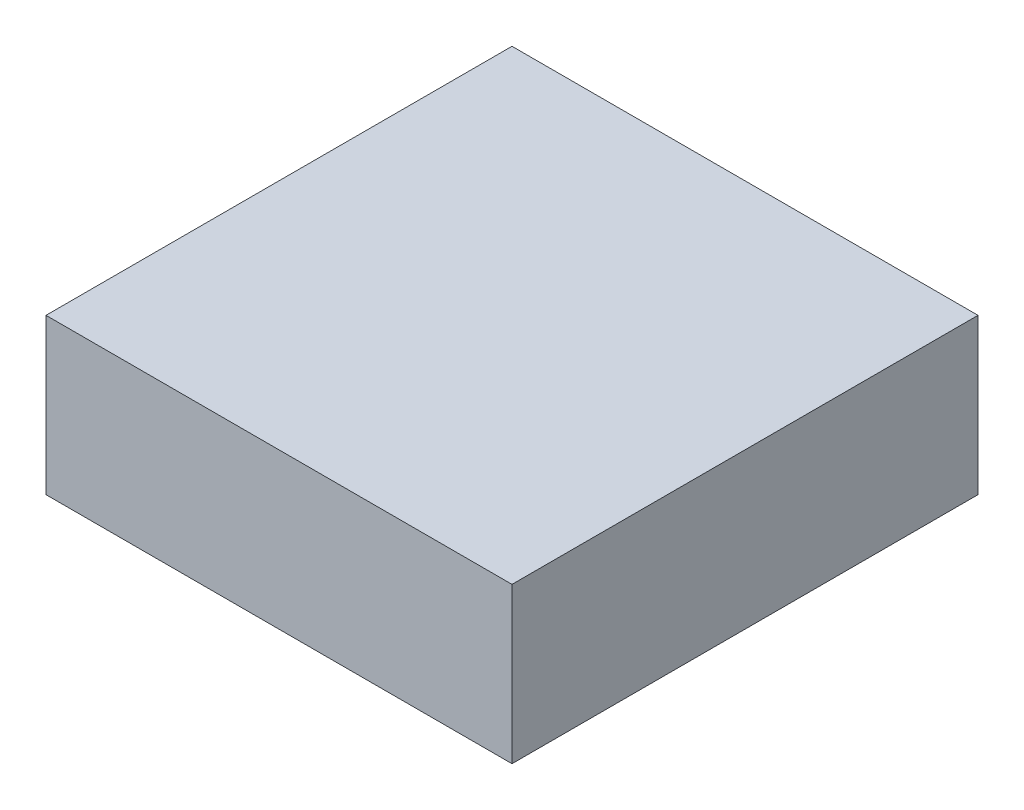
from build123d import *

# Parameters (mm, degrees)
SKETCH1_W           = 30
SKETCH1_H           = 30
BOSS_EXTRUDE1_DEPTH = 10


with BuildPart() as part:
    # Sketch1 → Boss-Extrude1 (new body)
    with BuildSketch(Plane(origin=(0, 0, 0), x_dir=(1, 0, 0), z_dir=(0, 1, 0))):
        Rectangle(SKETCH1_W, SKETCH1_H)
    extrude(amount=BOSS_EXTRUDE1_DEPTH)


solid = part.part
